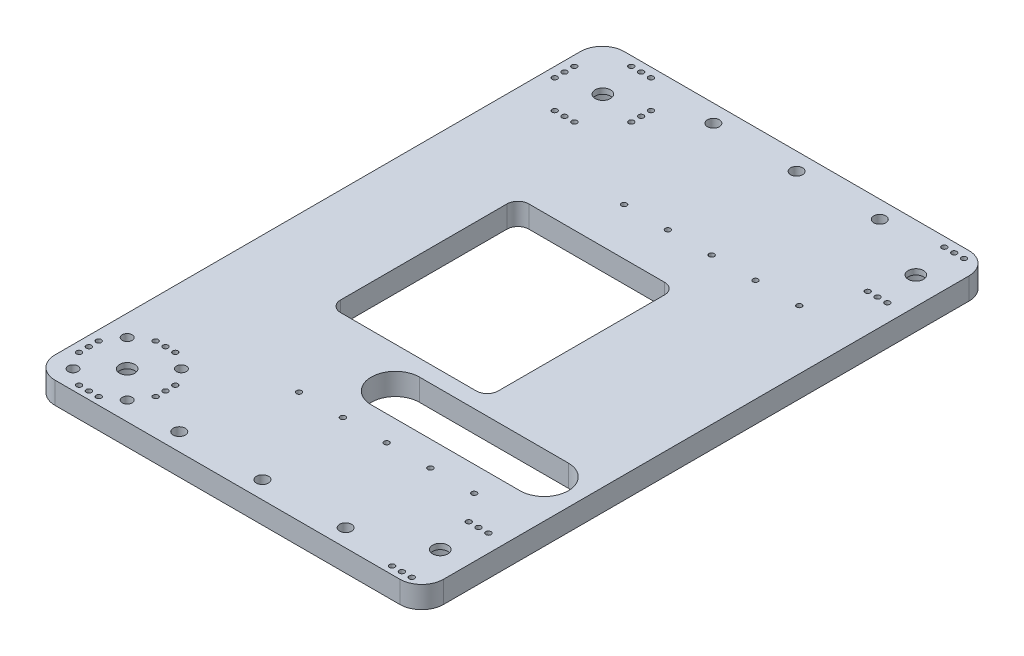
from build123d import *

# Parameters (mm, degrees)
BOSS_EXTRUDE1_DEPTH                                 = 10
CUT_EXTRUDE2_DEPTH                                  = 11
SKETCH5_R                                           = 9.5
CUT_EXTRUDE4_DEPTH                                  = 6.5
SKETCH7_R                                           = 8
CUT_EXTRUDE5_DEPTH                                  = 1
SKETCH8_R                                           = 3.5
CUT_EXTRUDE6_DEPTH                                  = 11
M4_CLEARANCE_HOLE1_D                                = 4.5
M2_CLEARANCE_HOLE1_D                                = 2.4
M2_CLEARANCE_HOLE2_D                                = 2.4
CSK_FOR_M2_COUNTERSUNK_FLAT_HEAD_SCREW1_D           = 2.4
CSK_FOR_M2_COUNTERSUNK_FLAT_HEAD_SCREW1_CSINK_D     = 4.4
CSK_FOR_M2_COUNTERSUNK_FLAT_HEAD_SCREW1_CSINK_ANGLE = 90
M5_CLEARANCE_HOLE1_D                                = 5.5


with BuildPart() as part:
    # Sketch1 → Boss-Extrude1 (new body)
    with BuildSketch(Plane(origin=(0, 0, 0), x_dir=(1, 0, 0), z_dir=(0, 1, 0))):
        with BuildLine():
            Line((10, 0), (167.5, 0))
            ThreePointArc((167.5, 0), (174.571067812, 2.928932188), (177.5, 10))
            Line((177.5, 10), (177.5, 250))
            ThreePointArc((177.5, 250), (174.571067812, 257.071067812), (167.5, 260))
            Line((167.5, 260), (10, 260))
            ThreePointArc((10, 260), (2.928932188, 257.071067812), (0, 250))
            Line((0, 250), (0, 10))
            ThreePointArc((0, 10), (2.928932188, 2.928932188), (10, 0))
        make_face()
        with BuildLine():
            Line((48.5, 91.94), (110.5, 91.94))
            ThreePointArc((110.5, 91.94), (114.035533906, 93.404466094), (115.5, 96.94))
            Line((115.5, 96.94), (115.5, 172.94))
            ThreePointArc((115.5, 172.94), (114.035533906, 176.475533906), (110.5, 177.94))
            Line((110.5, 177.94), (48.5, 177.94))
            ThreePointArc((48.5, 177.94), (44.964466094, 176.475533906), (43.5, 172.94))
            Line((43.5, 172.94), (43.5, 96.94))
            ThreePointArc((43.5, 96.94), (44.964466094, 93.404466094), (48.5, 91.94))
        make_face(mode=Mode.SUBTRACT)
    extrude(amount=BOSS_EXTRUDE1_DEPTH)

    # Sketch3 → Cut-Extrude2 (cut, through all)
    with BuildSketch(Plane(origin=(0, 10, 0), x_dir=(1, 0, 0), z_dir=(0, 1, 0))):
        with BuildLine():
            Line((92, 84.46), (160, 84.46))
            ThreePointArc((160, 84.46), (171, 73.46), (160, 62.46))
            Line((160, 62.46), (92, 62.46))
            ThreePointArc((92, 62.46), (81, 73.46), (92, 84.46))
        make_face()
    extrude(amount=-CUT_EXTRUDE2_DEPTH, mode=Mode.SUBTRACT)

    # Sketch5 → Cut-Extrude4 (cut)
    with BuildSketch(Plane(origin=(0, 0, 0), x_dir=(1, 0, 0), z_dir=(0, 1, 0))):
        with Locations(Location((22, 20.97, 0), (0, 0, 270))):  # turned: the seam where the file's is
            Circle(SKETCH5_R)
        with Locations(Location((165, 20.97, 0), (0, 0, 270))):  # turned: the seam where the file's is
            Circle(SKETCH5_R)
        with Locations(Location((165, 238.23, 0), (0, 0, 270))):  # turned: the seam where the file's is
            Circle(SKETCH5_R)
        with Locations(Location((22, 238.23, 0), (0, 0, 270))):  # turned: the seam where the file's is
            Circle(SKETCH5_R)
    extrude(amount=CUT_EXTRUDE4_DEPTH, mode=Mode.SUBTRACT)

    # Sketch7 → Cut-Extrude5 (cut)
    with BuildSketch(Plane(origin=(0, 6.5, 0), x_dir=(1, 0, 0), z_dir=(0, 1, 0))):
        with Locations(Location((22, 20.97, 0), (0, 0, 270))):  # turned: the seam where the file's is
            Circle(SKETCH7_R)
        with Locations(Location((165, 20.97, 0), (0, 0, 270))):  # turned: the seam where the file's is
            Circle(SKETCH7_R)
        with Locations(Location((165, 238.23, 0), (0, 0, 270))):  # turned: the seam where the file's is
            Circle(SKETCH7_R)
        with Locations(Location((22, 238.23, 0), (0, 0, 270))):  # turned: the seam where the file's is
            Circle(SKETCH7_R)
    extrude(amount=CUT_EXTRUDE5_DEPTH, mode=Mode.SUBTRACT)

    # Sketch8 → Cut-Extrude6 (cut, through all)
    with BuildSketch(Plane(origin=(0, 10, 0), x_dir=(1, 0, 0), z_dir=(0, 1, 0))):
        with Locations(Location((22, 20.97, 0), (0, 0, 270))):  # turned: the seam where the file's is
            Circle(SKETCH8_R)
        with Locations(Location((165, 20.97, 0), (0, 0, 270))):  # turned: the seam where the file's is
            Circle(SKETCH8_R)
        with Locations(Location((165, 238.23, 0), (0, 0, 270))):  # turned: the seam where the file's is
            Circle(SKETCH8_R)
        with Locations(Location((22, 238.23, 0), (0, 0, 270))):  # turned: the seam where the file's is
            Circle(SKETCH8_R)
    extrude(amount=-CUT_EXTRUDE6_DEPTH, mode=Mode.SUBTRACT)

    # M4 Clearance Hole1 (through all)
    with Locations(Plane(origin=(0, 10, 0), x_dir=(-1, 0, 0), z_dir=(0, 1, 0))):
        with Locations((-9.625631329, -33.344368671), (-34.374368671, -33.344368671), (-34.374368671, -8.595631329), (-9.625631329, -8.595631329)):
            Hole(M4_CLEARANCE_HOLE1_D / 2)

    # M2 Clearance Hole1 (through all)
    with Locations(Plane(origin=(0, 10, 0), x_dir=(-1, 0, 0), z_dir=(0, 1, 0))):
        with Locations((-150.5, -50.96), (-130.5, -50.96), (-110.5, -50.96), (-90.5, -50.96), (-70.5, -50.96), (-70.5, -199.46), (-90.5, -199.46), (-110.5, -199.46), (-130.5, -199.46), (-150.5, -199.46)):
            Hole(M2_CLEARANCE_HOLE1_D / 2)

    # M2 Clearance Hole2 (through all)
    with Locations(Plane(origin=(0, 10, 0), x_dir=(-1, 0, 0), z_dir=(0, 1, 0))):
        with Locations((-165, -3.47), (-169.5, -3.47), (-160.5, -3.47), (-160.5, -38.47), (-169.5, -38.47), (-165, -38.47), (-165, -220.73), (-169.5, -220.73), (-160.5, -220.73), (-160.5, -255.73), (-169.5, -255.73), (-165, -255.73), (-39.5, -242.73), (-39.5, -233.73), (-39.5, -238.23), (-22, -255.73), (-17.5, -255.73), (-26.5, -255.73), (-26.5, -220.73), (-17.5, -220.73), (-22, -220.73), (-4.5, -238.23), (-4.5, -233.73), (-4.5, -242.73)):
            Hole(M2_CLEARANCE_HOLE2_D / 2)

    # CSK for M2 Countersunk Flat Head Screw1 (through all)
    with Locations(Plane.XZ):
        with Locations((17.5, -3.47), (22, -3.47), (26.5, -3.47), (39.5, -16.47), (39.5, -20.97), (39.5, -25.47), (4.5, -25.47), (4.5, -20.97), (4.5, -16.47), (26.5, -38.47), (22, -38.47), (17.5, -38.47)):
            CounterSinkHole(CSK_FOR_M2_COUNTERSUNK_FLAT_HEAD_SCREW1_D / 2, CSK_FOR_M2_COUNTERSUNK_FLAT_HEAD_SCREW1_CSINK_D / 2, counter_sink_angle=CSK_FOR_M2_COUNTERSUNK_FLAT_HEAD_SCREW1_CSINK_ANGLE)

    # M5 Clearance Hole1 (through all)
    with Locations(Plane(origin=(0, 10, 0), x_dir=(-1, 0, 0), z_dir=(0, 1, 0))):
        with Locations((-58.75, -8), (-96.75, -8), (-134.75, -8), (-134.75, -252), (-96.75, -252), (-58.75, -252)):
            Hole(M5_CLEARANCE_HOLE1_D / 2)


solid = part.part
